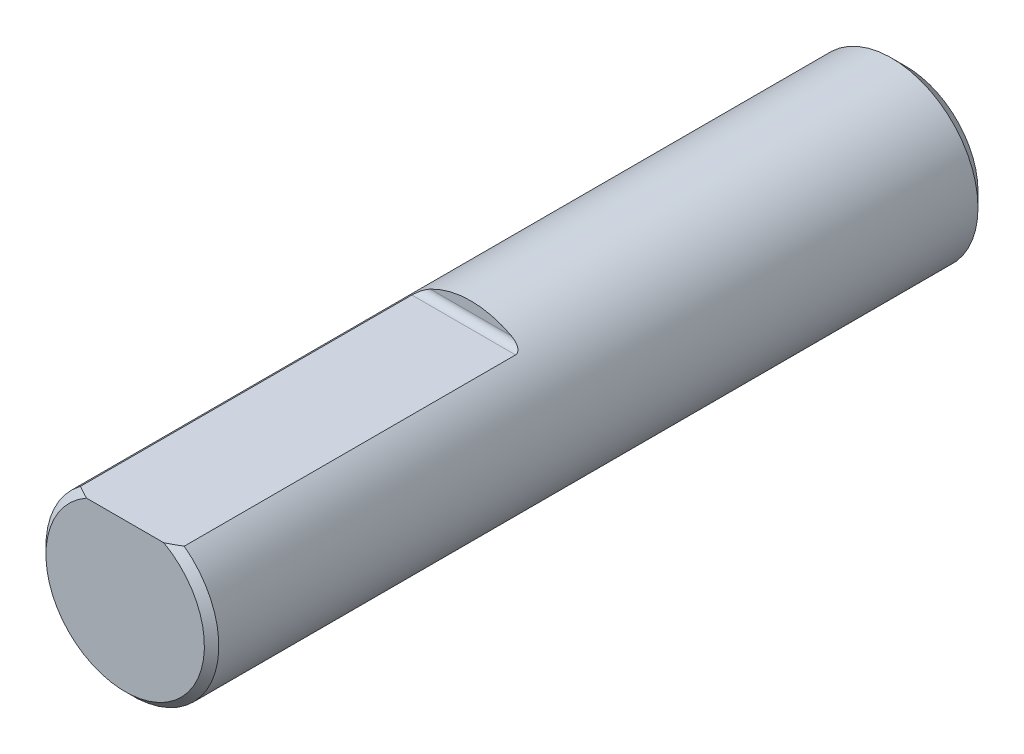
from build123d import *

# Parameters (mm, degrees)
CROQUIS1_R              = 3
SALIENTE_EXTRUIR1_DEPTH = 27.1
CORTAR_EXTRUIR1_DEPTH   = 12
CHAFL_N1_SIZE           = 0.25
CUT_EXTRUDE2_DEPTH      = 2.5
CHAMFER1_SIZE           = 0.5
FILLET1_R               = 0.25


with BuildPart() as part:
    # Croquis1 → Saliente-Extruir1 (new body)
    with BuildSketch(Plane.XY):
        Circle(CROQUIS1_R)
    extrude(amount=SALIENTE_EXTRUIR1_DEPTH)

    # Croquis2 → Cortar-Extruir1 (cut)
    with BuildSketch(Plane.XY.offset(27.1)):
        with BuildLine():
            Line((-1.8, 2.4), (1.8, 2.4))
            ThreePointArc((1.8, 2.4), (0, 3), (-1.8, 2.4))
        make_face()
    extrude(amount=-CORTAR_EXTRUIR1_DEPTH, mode=Mode.SUBTRACT)

    # Chaflán1
    chafl_n1_edges = [part.edges().sort_by_distance(p)[0] for p in [
        (-1.341640786, -2.683281573, 27.1),
    ]]
    chamfer(chafl_n1_edges, length=CHAFL_N1_SIZE)

    # Sketch1 → Cut-Extrude2 (cut)
    with BuildSketch(Plane(origin=(0, 0, 0), x_dir=(-1, 0, 0), z_dir=(0, 0, -1))):
        with BuildLine():
            Line((0, 0.75), (-0.661437828, 0.75))
            ThreePointArc((-0.661437828, 0.75), (0, -1), (0.661437828, 0.75))
            Line((0.661437828, 0.75), (0, 0.75))
        make_face()
    extrude(amount=-CUT_EXTRUDE2_DEPTH, mode=Mode.SUBTRACT)

    # Chamfer1
    chamfer1_edges = [part.edges().sort_by_distance(p)[0] for p in [
        (-3, 0, 0),
    ]]
    chamfer(chamfer1_edges, length=CHAMFER1_SIZE)

    # Fillet1
    fillet1_edges = [part.edges().sort_by_distance(p)[0] for p in [
        (0, 2.4, 15.1),
    ]]
    fillet(fillet1_edges, radius=FILLET1_R)


solid = part.part
